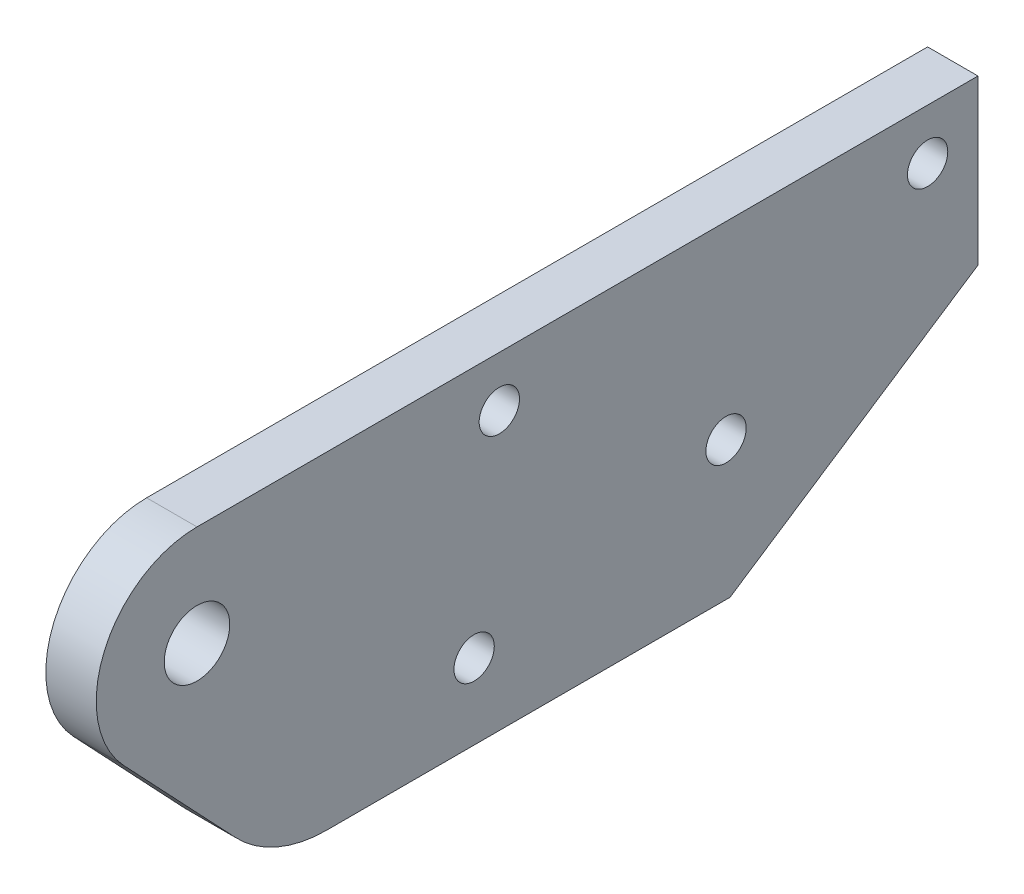
from build123d import *

# Parameters (mm, degrees)
SKETCH_1_R      = 1.6
SKETCH_1_R_2    = 2.6
EXTRUDE_1_DEPTH = 4


with BuildPart() as part:
    # 草图1 → 凸台-拉伸1 (new body)
    with BuildSketch(Plane(origin=(0, 0, 0), x_dir=(0, 0, -1), z_dir=(1, 0, 0))):
        with BuildLine():
            Line((8.104883027, 1.878840053), (27.795402052, 14.878840053))
            Line((27.795402052, 14.878840053), (27.795402052, 27.878840053))
            Line((27.795402052, 27.878840053), (-34.204597948, 27.878840053))
            ThreePointArc((-34.204597948, 27.878840053), (-41.551421317, 23.044939607), (-40.019791495, 14.384886649))
            Line((-40.019791495, 14.384886649), (-31.164108907, 5.011398298))
            ThreePointArc((-31.164108907, 5.011398298), (-27.852741415, 2.695310842), (-23.895116973, 1.878840053))
            Line((-23.895116973, 1.878840053), (8.104883027, 1.878840053))
        make_face()
        with Locations((23.795402052, 23.878840053)):
            Circle(SKETCH_1_R, mode=Mode.SUBTRACT)
        with Locations((-10.204597948, 23.878840053)):
            Circle(SKETCH_1_R, mode=Mode.SUBTRACT)
        with Locations((7.795402052, 12.878840053)):
            Circle(SKETCH_1_R, mode=Mode.SUBTRACT)
        with Locations((-12.204597948, 7.878840053)):
            Circle(SKETCH_1_R, mode=Mode.SUBTRACT)
        with Locations((-34.204597948, 19.878840053)):
            Circle(SKETCH_1_R_2, mode=Mode.SUBTRACT)
    extrude(amount=EXTRUDE_1_DEPTH)


solid = part.part
